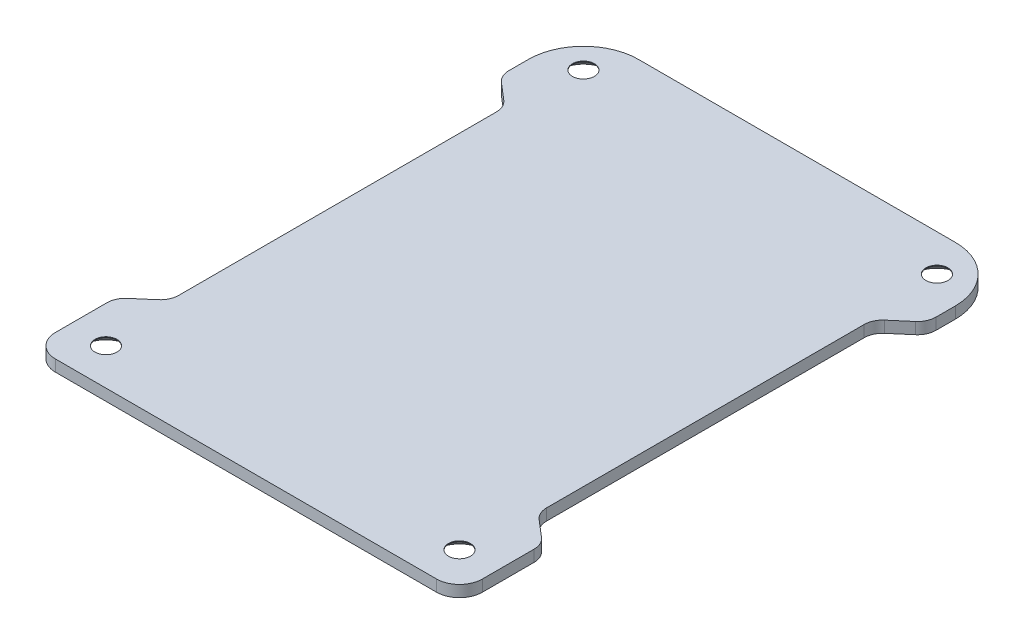
from build123d import *

# Parameters (mm, degrees)
SKETCH1_R           = 1.524
BOSS_EXTRUDE1_DEPTH = 1.5875
CHAMFER1_SIZE       = 1.7145
CHAMFER1_SIZE2      = 1.490392112


with BuildPart() as part:
    # Sketch1 → Boss-Extrude1 (new body)
    with BuildSketch(Plane(origin=(0, 0, 0), x_dir=(1, 0, 0), z_dir=(0, 1, 0))):
        with BuildLine():
            Line((-26.3525, -38.1), (26.3525, -38.1))
            ThreePointArc((26.3525, -38.1), (28.59756403, -37.17006403), (29.5275, -34.925))
            Line((29.5275, -34.925), (29.5275, -27.795278791))
            ThreePointArc((29.5275, -27.795278791), (29.294536895, -26.732649616), (28.638381288, -25.864944371))
            Line((28.638381288, -25.864944371), (26.334171426, -23.89431332))
            ThreePointArc((26.334171426, -23.89431332), (25.678015818, -23.026608076), (25.445052714, -21.9639789))
            Line((25.445052714, -21.9639789), (25.445052714, 21.9639789))
            ThreePointArc((25.445052714, 21.9639789), (25.678015818, 23.026608076), (26.334171426, 23.89431332))
            Line((26.334171426, 23.89431332), (28.638381288, 25.864944371))
            ThreePointArc((28.638381288, 25.864944371), (29.294536895, 26.732649616), (29.5275, 27.795278791))
            Line((29.5275, 27.795278791), (29.5275, 30.48))
            ThreePointArc((29.5275, 30.48), (27.295653673, 35.868153673), (21.9075, 38.1))
            Line((21.9075, 38.1), (-21.9075, 38.1))
            ThreePointArc((-21.9075, 38.1), (-27.295653673, 35.868153673), (-29.5275, 30.48))
            Line((-29.5275, 30.48), (-29.5275, 27.795278791))
            ThreePointArc((-29.5275, 27.795278791), (-29.294536895, 26.732649616), (-28.638381288, 25.864944371))
            Line((-28.638381288, 25.864944371), (-26.334171426, 23.89431332))
            ThreePointArc((-26.334171426, 23.89431332), (-25.678015818, 23.026608076), (-25.445052714, 21.9639789))
            Line((-25.445052714, 21.9639789), (-25.445052714, -21.9639789))
            ThreePointArc((-25.445052714, -21.9639789), (-25.678015818, -23.026608076), (-26.334171426, -23.89431332))
            Line((-26.334171426, -23.89431332), (-28.638381288, -25.864944371))
            ThreePointArc((-28.638381288, -25.864944371), (-29.294536895, -26.732649616), (-29.5275, -27.795278791))
            Line((-29.5275, -27.795278791), (-29.5275, -34.925))
            ThreePointArc((-29.5275, -34.925), (-28.59756403, -37.17006403), (-26.3525, -38.1))
        make_face()
        with Locations((24.4475, 33.02)):
            Circle(SKETCH1_R, mode=Mode.SUBTRACT)
        with Locations((-24.4475, -33.02)):
            Circle(SKETCH1_R, mode=Mode.SUBTRACT)
        with Locations((-24.4475, 33.02)):
            Circle(SKETCH1_R, mode=Mode.SUBTRACT)
        with Locations((24.4475, -33.02)):
            Circle(SKETCH1_R, mode=Mode.SUBTRACT)
    extrude(amount=BOSS_EXTRUDE1_DEPTH)

    # Chamfer1
    chamfer1_edges = [part.edges().sort_by_distance(p)[0] for p in [
        (22.9235, 0, -33.02),
        (-25.9715, 0, 33.02),
        (-25.9715, 0, -33.02),
        (22.9235, 0, 33.02),
    ]]
    chamfer1_side = [part.faces().sort_by_distance(p)[0] for p in [
        (0, 0, 0.184699289),
    ]]
    chamfer(chamfer1_edges, length=CHAMFER1_SIZE, length2=CHAMFER1_SIZE2, reference=chamfer1_side[0])


solid = part.part
